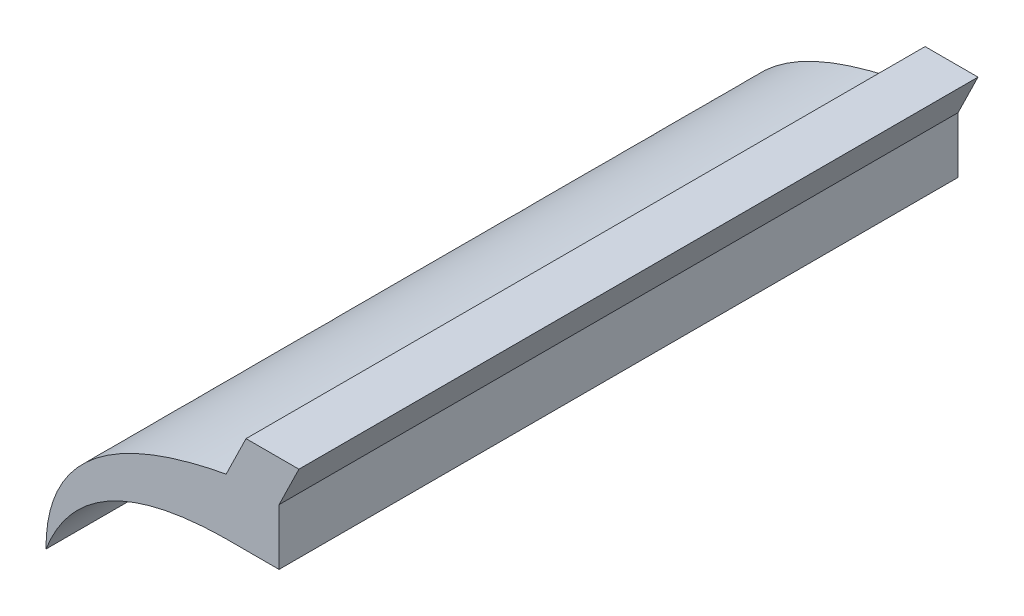
from build123d import *

# Parameters (mm, degrees)
SKETCH1_W           = 58.430021541
SKETCH1_H           = 61.949414885
BOSS_EXTRUDE1_DEPTH = 750


with BuildPart() as part:
    # Sketch1 → Boss-Extrude1 (new body)
    with BuildSketch(Plane.XY):
        with BuildLine():
            add(Edge.make_bspline(
                [(-99.527538728, 54.459896253), (-100.331758171, 188.294424486), (99.44017176, 225.622803561)],
                knots=[0, 0, 0, 1, 1, 1], degree=2))
            Line((99.44017176, 225.622803561), (99.44017176, 163.673388676))
            add(Edge.make_bspline(
                [(-99.527538728, 54.459896253), (-58.241038514, 162.199954542), (99.44017176, 163.673388676)],
                knots=[0, 0, 0, 1, 1, 1], degree=2))
        make_face()
        with Locations((128.655182531, 194.648096119)):
            Rectangle(SKETCH1_W, SKETCH1_H)
        Polygon((99.44017176, 225.622803561), (121.383239857, 270.550542905), (179.813261398, 270.550542905), (157.870193301, 225.622803561), align=None)
    extrude(amount=BOSS_EXTRUDE1_DEPTH)


solid = part.part
